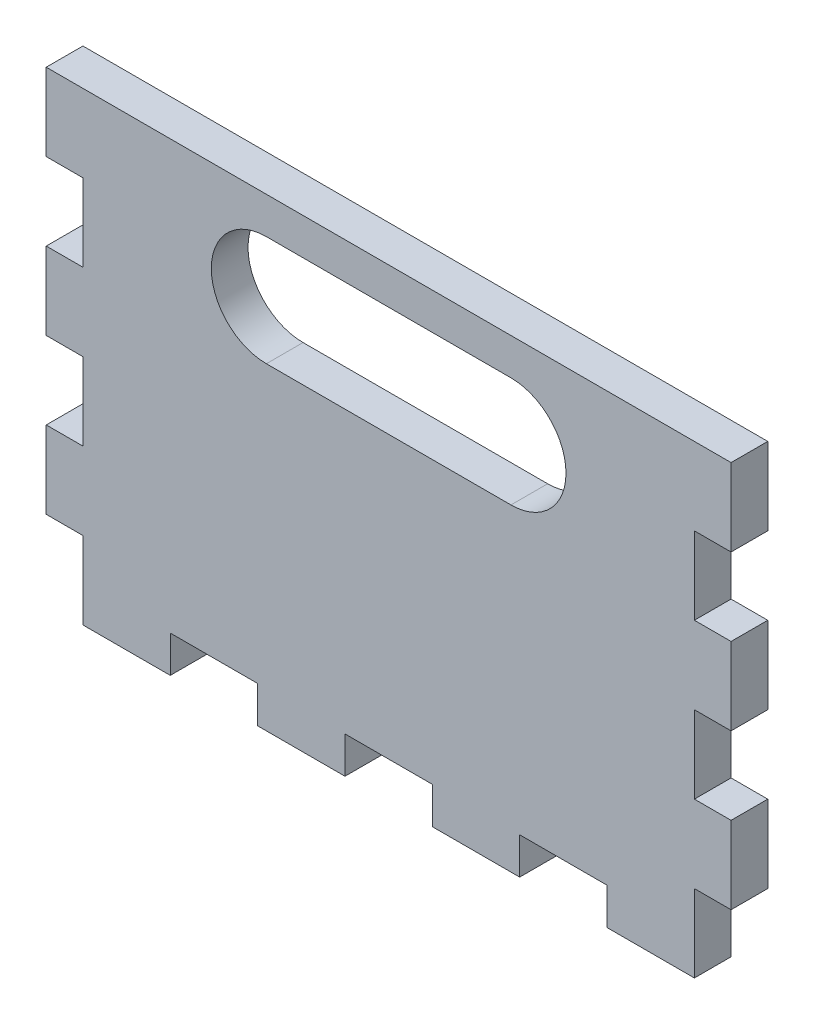
from build123d import *

# Parameters (mm, degrees)
ESTRUSIONE_ESTRUSIONE1_DEPTH = 1.5


with BuildPart() as part:
    # Schizzo1 → Estrusione-Estrusione1 (new body, symmetric)
    with BuildSketch(Plane.XY):
        Polygon((25, 17.5), (28, 17.5), (28, 11.166666667), (25, 11.166666667), (25, 4.833333333), (28, 4.833333333), (28, -1.5), (25, -1.5), (25, -7.833333333), (28, -7.833333333), (28, -14.166666667), (25, -14.166666667), (25, -20.5), (17.857142857, -20.5), (17.857142857, -17.5), (10.714285714, -17.5), (10.714285714, -20.5), (3.571428571, -20.5), (3.571428571, -17.5), (-3.571428571, -17.5), (-3.571428571, -20.5), (-10.714285714, -20.5), (-10.714285714, -17.5), (-17.857142857, -17.5), (-17.857142857, -20.5), (-25, -20.5), (-25, -14.166666667), (-28, -14.166666667), (-28, -7.833333333), (-25, -7.833333333), (-25, -1.5), (-28, -1.5), (-28, 4.833333333), (-25, 4.833333333), (-25, 11.166666667), (-28, 11.166666667), (-28, 17.5), (-25, 17.5), align=None)
        with BuildLine():
            Line((-10, 14.5), (10, 14.5))
            ThreePointArc((10, 14.5), (14.5, 10), (10, 5.5))
            Line((10, 5.5), (-10, 5.5))
            ThreePointArc((-10, 5.5), (-14.5, 10), (-10, 14.5))
        make_face(mode=Mode.SUBTRACT)
    extrude(amount=ESTRUSIONE_ESTRUSIONE1_DEPTH, both=True)


solid = part.part
